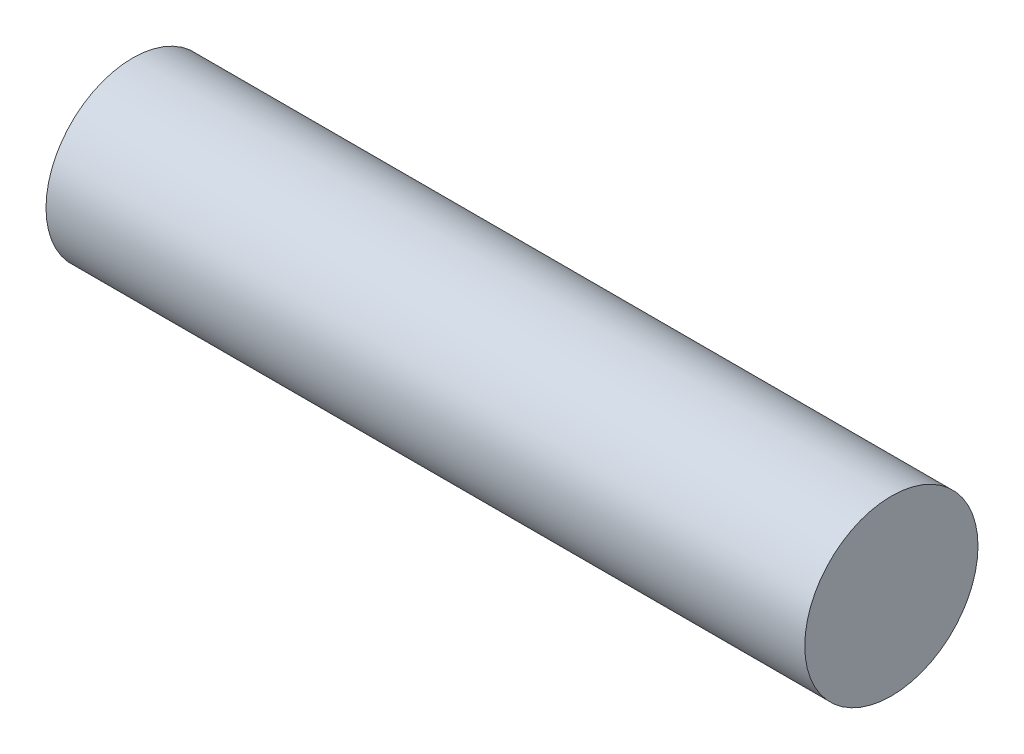
from build123d import *

# Parameters (mm, degrees)
SKETCH1_R           = 6.35
BOSS_EXTRUDE1_DEPTH = 55.626
SKETCH2_R           = 3.17881
CUT_EXTRUDE1_DEPTH  = 12.7


with BuildPart() as part:
    # Sketch1 → Boss-Extrude1 (new body)
    with BuildSketch(Plane(origin=(0, 0, 0), x_dir=(0, 0, -1), z_dir=(1, 0, 0))):
        Circle(SKETCH1_R)
    extrude(amount=BOSS_EXTRUDE1_DEPTH)

    # Sketch2 → Cut-Extrude1 (cut)
    with BuildSketch(Plane.ZY):
        Circle(SKETCH2_R)
    extrude(amount=-CUT_EXTRUDE1_DEPTH, mode=Mode.SUBTRACT)


solid = part.part
